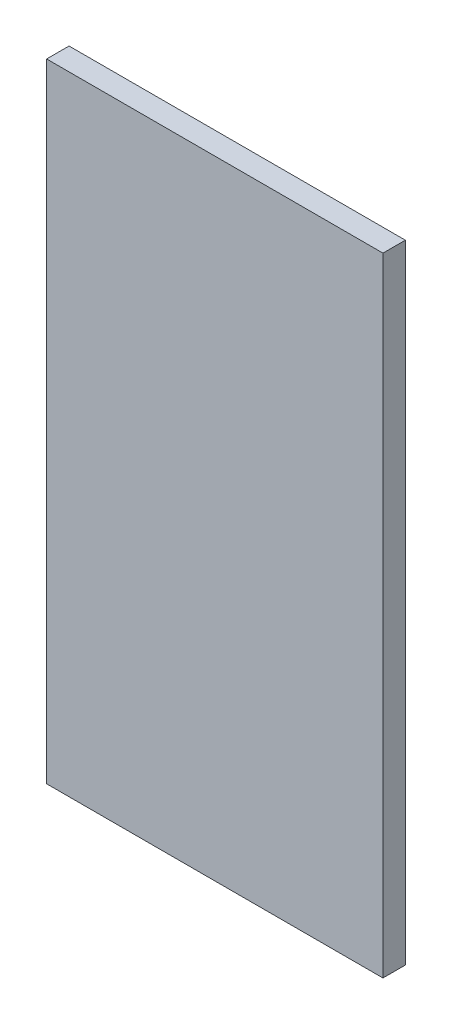
from build123d import *

# Parameters (mm, degrees)
SKETCH1_W           = 95.25
SKETCH1_H           = 177.8
BOSS_EXTRUDE1_DEPTH = 6.35


with BuildPart() as part:
    # Sketch1 → Boss-Extrude1 (new body)
    with BuildSketch(Plane.XY):
        with Locations((47.625, 88.9)):
            Rectangle(SKETCH1_W, SKETCH1_H)
    extrude(amount=BOSS_EXTRUDE1_DEPTH)


solid = part.part
